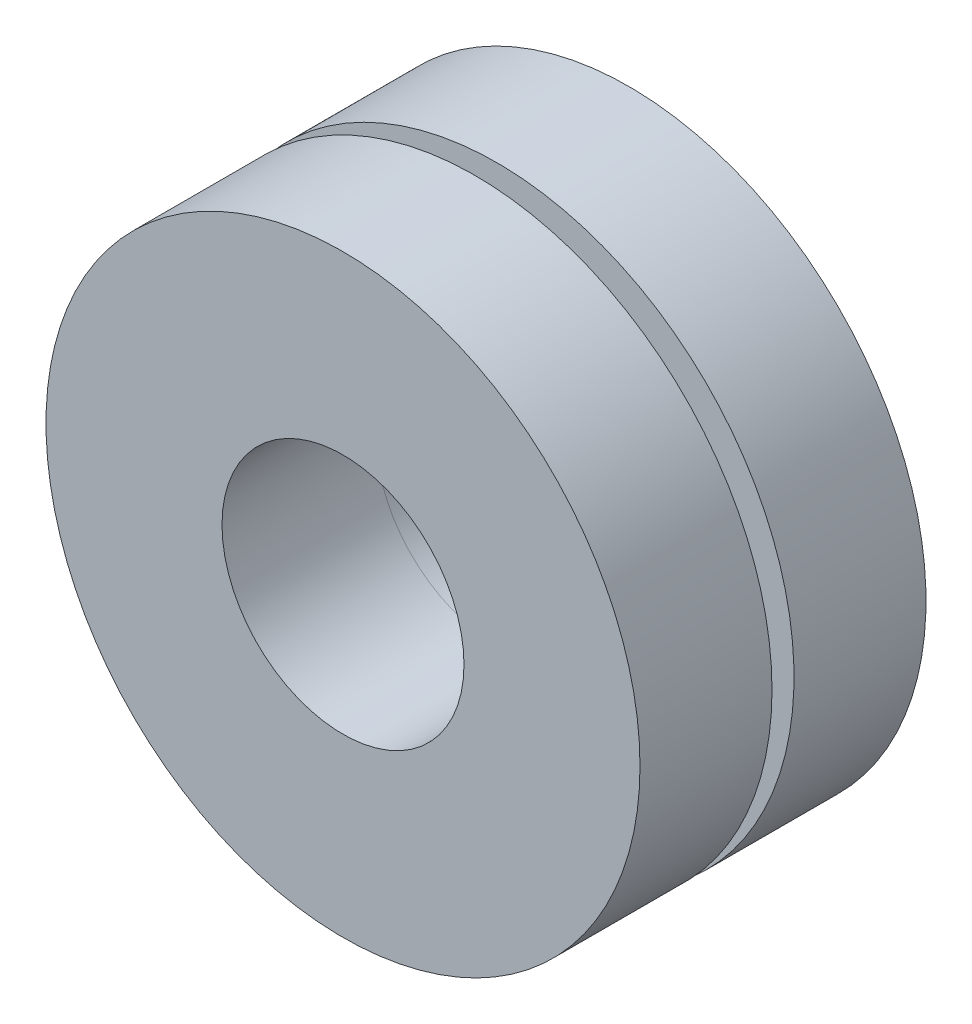
from build123d import *

# Parameters (mm, degrees)
SKETCH1_R           = 4.572
SKETCH1_R_2         = 2.794
BOSS_EXTRUDE2_DEPTH = 0.508
SKETCH3_R           = 6.858
SKETCH3_R_2         = 2.794
BOSS_EXTRUDE3_DEPTH = 3.048
SKETCH4_R           = 6.858
SKETCH4_R_2         = 2.794
BOSS_EXTRUDE4_DEPTH = 3.048


with BuildPart() as part:
    # Sketch1 → Boss-Extrude2 (new body)
    with BuildSketch(Plane.XY):
        Circle(SKETCH1_R)
        Circle(SKETCH1_R_2, mode=Mode.SUBTRACT)
    extrude(amount=BOSS_EXTRUDE2_DEPTH)

    # Sketch3 → Boss-Extrude3 (add)
    with BuildSketch(Plane.XY.offset(0.508)):
        Circle(SKETCH3_R)
        Circle(SKETCH3_R_2, mode=Mode.SUBTRACT)
    extrude(amount=BOSS_EXTRUDE3_DEPTH)


with BuildPart() as body_2:
    # Sketch4 → Boss-Extrude4 (new body)
    with BuildSketch(Plane(origin=(0, 0, 0), x_dir=(-1, 0, 0), z_dir=(0, 0, -1))):
        Circle(SKETCH4_R)
        Circle(SKETCH4_R_2, mode=Mode.SUBTRACT)
    extrude(amount=BOSS_EXTRUDE4_DEPTH)


solid = Compound([part.part, body_2.part])
